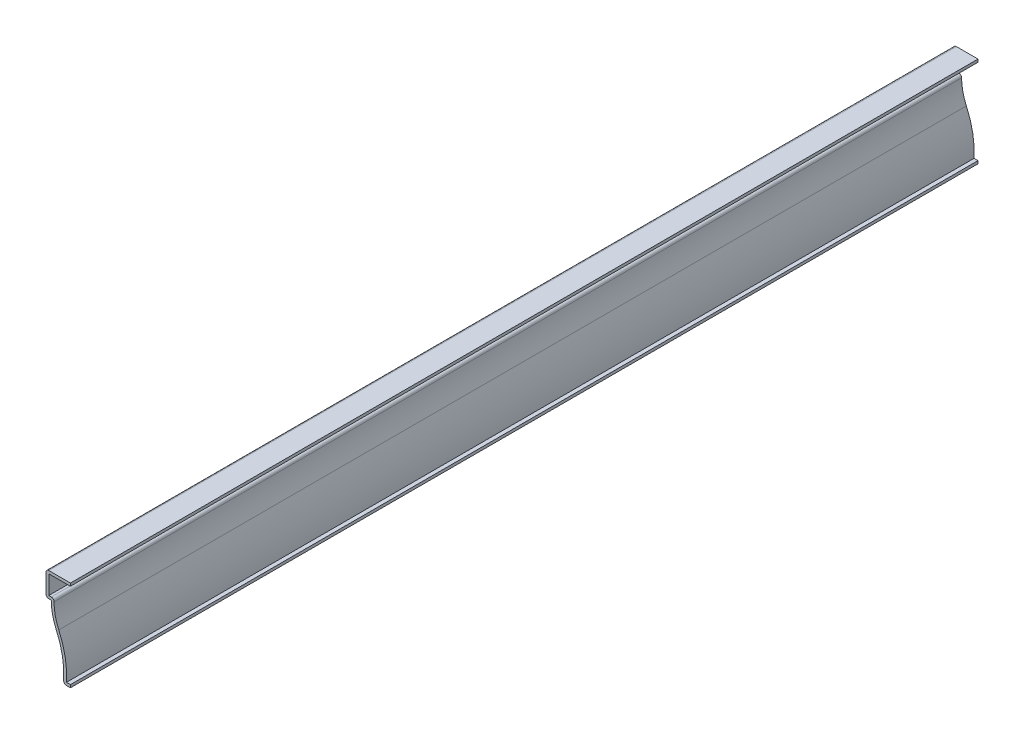
from build123d import *

# Parameters (mm, degrees)
EXTRUDE_THIN1_DEPTH = 412.75
FILLET1_R           = 1.27


with BuildPart() as part:
    # Sketch1 → Extrude-Thin1 (new body)
    with BuildSketch(Plane.XY):
        with BuildLine():
            Line((0, 0), (-3.175, 0))
            ThreePointArc((-3.175, 0), (-3.520818221, 10.038169204), (-6.451518656, 19.645220062))
            ThreePointArc((-6.451518656, 19.645220062), (-8.154775373, 24.78173908), (-8.73125, 30.1625))
            Line((-8.73125, 30.1625), (-11.1125, 30.1625))
            Line((-11.1125, 30.1625), (-11.1125, 41.275))
            Line((-11.1125, 41.275), (0, 41.275))
            Line((0, 41.275), (0, 40.005))
            Line((0, 40.005), (-9.8425, 40.005))
            Line((-9.8425, 40.005), (-9.8425, 31.4325))
            Line((-9.8425, 31.4325), (-7.42780577, 31.4325))
            ThreePointArc((-7.42780577, 31.4325), (-7.03999205, 25.673351928), (-5.295505223, 20.171084059))
            ThreePointArc((-5.295505223, 20.171084059), (-2.389045241, 10.934858222), (-1.80091866, 1.27))
            Line((-1.80091866, 1.27), (0, 1.27))
            Line((0, 1.27), (0, 0))
        make_face()
    extrude(amount=-EXTRUDE_THIN1_DEPTH)

    # Fillet1
    fillet1_edges = [part.edges().sort_by_distance(p)[0] for p in [
        (-7.42780577, 31.4325, -206.375),
        (-3.175, 0, -206.375),
        (-11.1125, 30.1625, -206.375),
        (-11.1125, 41.275, -206.375),
    ]]
    fillet(fillet1_edges, radius=FILLET1_R)


solid = part.part
